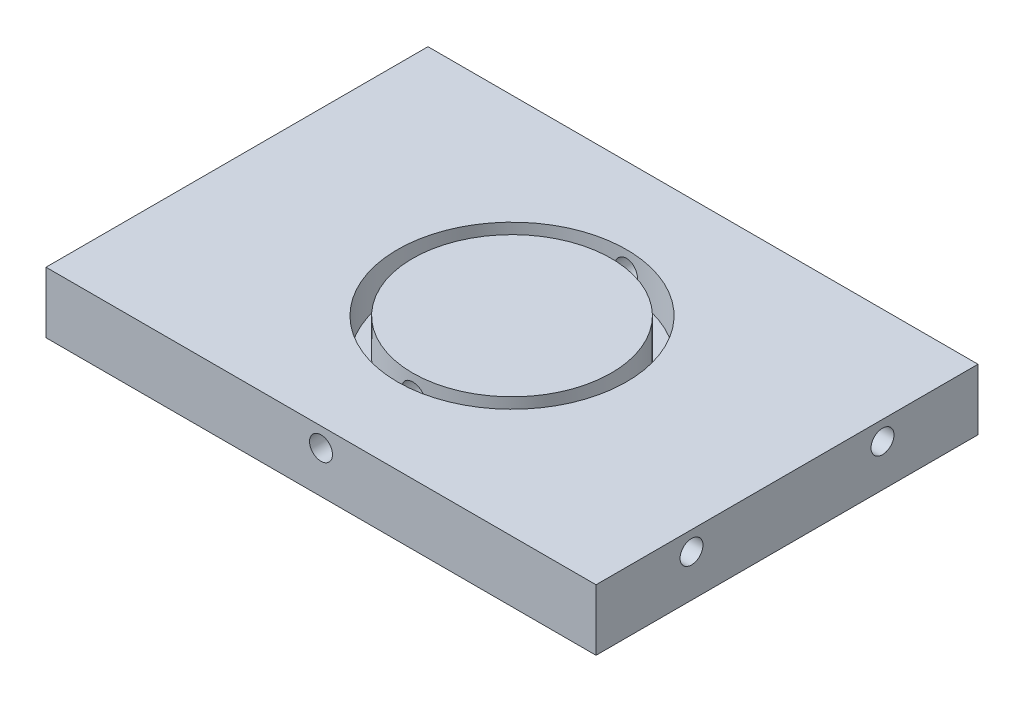
from build123d import *

# Parameters (mm, degrees)
ESQUISSE1_W             = 72
ESQUISSE1_H             = 8
BOSS_EXTRU_1_DEPTH      = 50
ESQUISSE2_R             = 15
ESQUISSE2_R_2           = 13
ENL_V_MAT_EXTRU_1_DEPTH = 5
ESQUISSE3_R             = 1.5
ENL_V_MAT_EXTRU_2_DEPTH = 10
ESQUISSE4_R             = 1.5
ENL_V_MAT_EXTRU_3_DEPTH = 10
ESQUISSE5_R             = 1.5
ENL_V_MAT_EXTRU_4_DEPTH = 51


with BuildPart() as part:
    # Esquisse1 → Boss.-Extru.1 (new body)
    with BuildSketch(Plane.XY):
        with Locations((30.5, -49)):
            Rectangle(ESQUISSE1_W, ESQUISSE1_H)
    extrude(amount=BOSS_EXTRU_1_DEPTH)

    # Esquisse2 → Enlèv. mat.-Extru.1 (cut)
    with BuildSketch(Plane(origin=(0, -45, 0), x_dir=(-1, 0, 0), z_dir=(0, 1, 0))):
        with Locations((-30.5, 25)):
            Circle(ESQUISSE2_R)
        with Locations((-30.5, 25)):
            Circle(ESQUISSE2_R_2, mode=Mode.SUBTRACT)
    extrude(amount=-ENL_V_MAT_EXTRU_1_DEPTH, mode=Mode.SUBTRACT)

    # Esquisse3 → Enlèv. mat.-Extru.2 (cut)
    with BuildSketch(Plane.ZY.offset(5.5)):
        with Locations((12.5, -47.5)):
            Circle(ESQUISSE3_R)
        with Locations((37.5, -47.5)):
            Circle(ESQUISSE3_R)
    extrude(amount=-ENL_V_MAT_EXTRU_2_DEPTH, mode=Mode.SUBTRACT)

    # Esquisse4 → Enlèv. mat.-Extru.3 (cut)
    with BuildSketch(Plane(origin=(66.5, 0, 0), x_dir=(0, 0, -1), z_dir=(1, 0, 0))):
        with Locations((-37.5, -47.5)):
            Circle(ESQUISSE4_R)
        with Locations((-12.5, -47.5)):
            Circle(ESQUISSE4_R)
    extrude(amount=-ENL_V_MAT_EXTRU_3_DEPTH, mode=Mode.SUBTRACT)

    # Esquisse5 → Enlèv. mat.-Extru.4 (cut, through all)
    with BuildSketch(Plane(origin=(0, 0, 0), x_dir=(-1, 0, 0), z_dir=(0, 0, -1))):
        with Locations((-30.5, -47.5)):
            Circle(ESQUISSE5_R)
    extrude(amount=-ENL_V_MAT_EXTRU_4_DEPTH, mode=Mode.SUBTRACT)


solid = part.part
